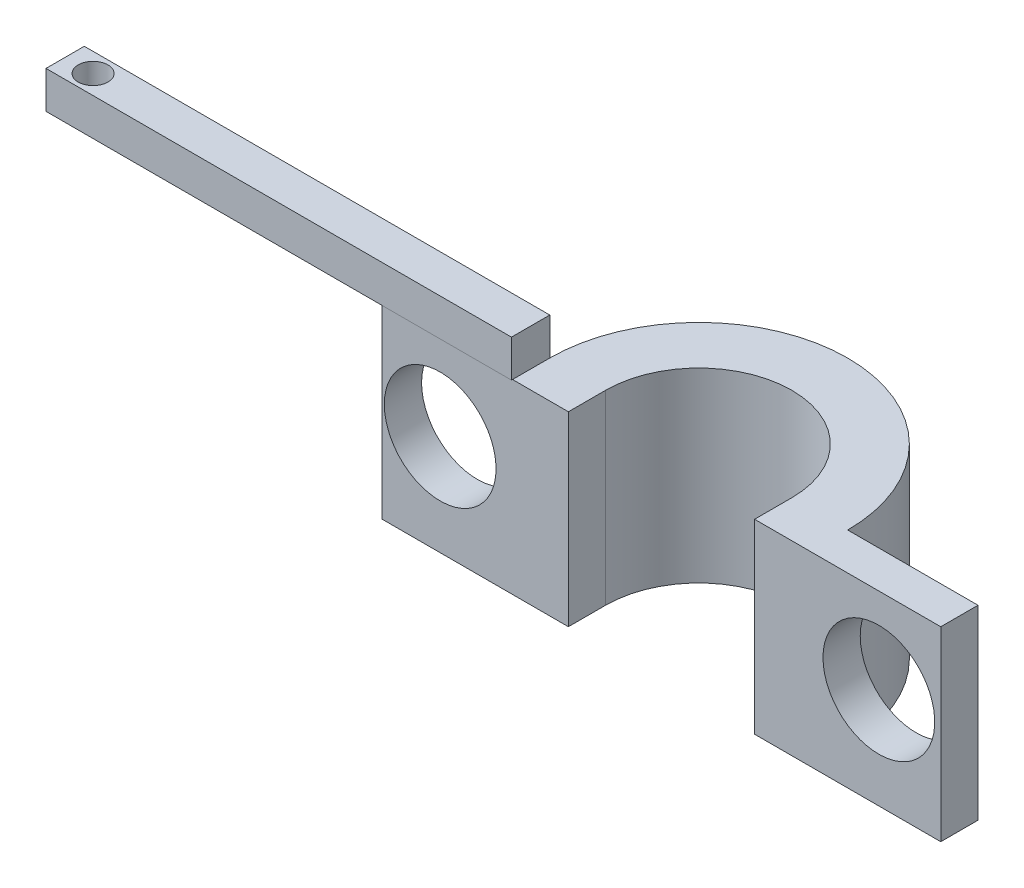
from build123d import *

# Parameters (mm, degrees)
SKETCH2_R           = 8
SKETCH2_R_2         = 5
EXTRUDE_THIN1_DEPTH = 10
CUT_EXTRUDE1_DEPTH  = 10
SKETCH4_W           = 10
SKETCH4_H           = 10
BOSS_EXTRUDE1_DEPTH = 2
SKETCH5_R           = 3
CUT_EXTRUDE2_DEPTH  = 2
SKETCH6_W           = 25
SKETCH6_H           = 2.057623051
BOSS_EXTRUDE2_DEPTH = 2
SKETCH7_R           = 0.8
CUT_EXTRUDE3_DEPTH  = 2


with BuildPart() as part:
    # Sketch2 → Extrude-Thin1 (new body)
    with BuildSketch(Plane(origin=(0, 0, 0), x_dir=(1, 0, 0), z_dir=(0, 1, 0))):
        Circle(SKETCH2_R)
        Circle(SKETCH2_R_2, mode=Mode.SUBTRACT)
    extrude(amount=EXTRUDE_THIN1_DEPTH)

    # Sketch3 → Cut-Extrude1 (cut)
    with BuildSketch(Plane(origin=(0, 10, 0), x_dir=(1, 0, 0), z_dir=(0, 1, 0))):
        with BuildLine():
            Line((-8, 0), (8, 0))
            ThreePointArc((8, 0), (0, -8), (-8, 0))
        make_face()
    extrude(amount=-CUT_EXTRUDE1_DEPTH, mode=Mode.SUBTRACT)

    # Sketch4 → Boss-Extrude1 (add)
    with BuildSketch(Plane.XY):
        with Locations((10, 5)):
            Rectangle(SKETCH4_W, SKETCH4_H)
        with Locations((-10, 5)):
            Rectangle(SKETCH4_W, SKETCH4_H)
    extrude(amount=BOSS_EXTRUDE1_DEPTH)

    # Sketch5 → Cut-Extrude2 (cut)
    with BuildSketch(Plane(origin=(0, 0, 0), x_dir=(-1, 0, 0), z_dir=(0, 0, -1))):
        with Locations((-11.674262076, 5.406814048)):
            Circle(SKETCH5_R)
        with Locations((11.885931395, 5.406814048)):
            Circle(SKETCH5_R)
    extrude(amount=-CUT_EXTRUDE2_DEPTH, mode=Mode.SUBTRACT)

    # Sketch6 → Boss-Extrude2 (add)
    with BuildSketch(Plane(origin=(0, 10, 0), x_dir=(1, 0, 0), z_dir=(0, 1, 0))):
        with Locations((-20.5, -1.028811526)):
            Rectangle(SKETCH6_W, SKETCH6_H)
    extrude(amount=BOSS_EXTRUDE2_DEPTH)

    # Sketch7 → Cut-Extrude3 (cut)
    with BuildSketch(Plane(origin=(0, 12, 0), x_dir=(1, 0, 0), z_dir=(0, 1, 0))):
        with Locations((-31.5, -1.029261487)):
            Circle(SKETCH7_R)
    extrude(amount=-CUT_EXTRUDE3_DEPTH, mode=Mode.SUBTRACT)


solid = part.part
